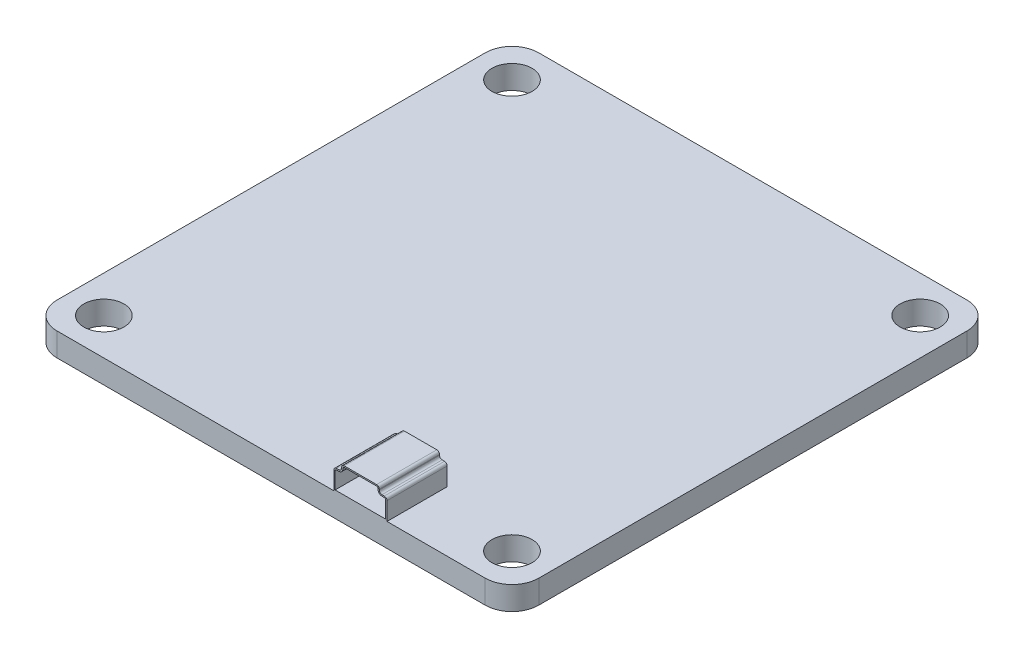
from build123d import *

# Parameters (mm, degrees)
SKETCH1_R           = 1.5
BOSS_EXTRUDE1_DEPTH = 1.75
BOSS_DEPTH          = 3
BOSS_EXTRUDE5_DEPTH = 1.5
SKETCH10_R          = 0.25
CUT_EXTRUDE2_DEPTH  = 5.5


with BuildPart() as part:
    # Sketch1 → Boss-Extrude1 (new body)
    with BuildSketch(Plane(origin=(0, 0, 0), x_dir=(1, 0, 0), z_dir=(0, 1, 0))):
        with BuildLine():
            Line((-16, -18), (16, -18))
            ThreePointArc((16, -18), (17.414213562, -17.414213562), (18, -16))
            Line((18, -16), (18, 16))
            ThreePointArc((18, 16), (17.414213562, 17.414213562), (16, 18))
            Line((16, 18), (-16, 18))
            ThreePointArc((-16, 18), (-17.414213562, 17.414213562), (-18, 16))
            Line((-18, 16), (-18, -16))
            ThreePointArc((-18, -16), (-17.414213562, -17.414213562), (-16, -18))
        make_face()
        with Locations((-15.25, 15.25)):
            Circle(SKETCH1_R, mode=Mode.SUBTRACT)
        with Locations((15.25, 15.25)):
            Circle(SKETCH1_R, mode=Mode.SUBTRACT)
        with Locations((-15.25, -15.25)):
            Circle(SKETCH1_R, mode=Mode.SUBTRACT)
        with Locations((15.25, -15.25)):
            Circle(SKETCH1_R, mode=Mode.SUBTRACT)
    extrude(amount=BOSS_EXTRUDE1_DEPTH)

    # Sketch2 → Boss- (add)
    with BuildSketch(Plane.XY.offset(18)):
        with BuildLine():
            Line((4.683071404, 1.75), (8.659974309, 1.75))
            Line((8.659974309, 1.75), (8.659974309, 3.094003243))
            ThreePointArc((8.659974309, 3.094003243), (8.601395665, 3.235424599), (8.459974309, 3.294003243))
            Line((8.459974309, 3.294003243), (8.281537536, 3.294003243))
            ThreePointArc((8.281537536, 3.294003243), (8.14011618, 3.352581887), (8.081537536, 3.494003243))
            Line((8.081537536, 3.494003243), (8.081537536, 3.55))
            ThreePointArc((8.081537536, 3.55), (8.022958893, 3.691421356), (7.881537536, 3.75))
            Line((7.881537536, 3.75), (5.461508176, 3.75))
            ThreePointArc((5.461508176, 3.75), (5.32008682, 3.691421356), (5.261508176, 3.55))
            Line((5.261508176, 3.55), (5.261508176, 3.494003243))
            ThreePointArc((5.261508176, 3.494003243), (5.202929533, 3.352581887), (5.061508176, 3.294003243))
            Line((5.061508176, 3.294003243), (4.883071404, 3.294003243))
            ThreePointArc((4.883071404, 3.294003243), (4.741650048, 3.235424599), (4.683071404, 3.094003243))
            Line((4.683071404, 3.094003243), (4.683071404, 1.75))
        make_face()
        with BuildLine():
            Line((4.783071404, 1.85), (4.783071404, 3.094003243))
            ThreePointArc((4.783071404, 3.094003243), (4.812360726, 3.164713921), (4.883071404, 3.194003243))
            Line((4.883071404, 3.194003243), (5.061508176, 3.194003243))
            ThreePointArc((5.061508176, 3.194003243), (5.273640211, 3.281871209), (5.361508176, 3.494003243))
            Line((5.361508176, 3.494003243), (5.361508176, 3.55))
            ThreePointArc((5.361508176, 3.55), (5.390797498, 3.620710678), (5.461508176, 3.65))
            Line((5.461508176, 3.65), (7.881537536, 3.65))
            ThreePointArc((7.881537536, 3.65), (7.952248214, 3.620710678), (7.981537536, 3.55))
            Line((7.981537536, 3.55), (7.981537536, 3.494003243))
            ThreePointArc((7.981537536, 3.494003243), (8.069405502, 3.281871209), (8.281537536, 3.194003243))
            Line((8.281537536, 3.194003243), (8.459974309, 3.194003243))
            ThreePointArc((8.459974309, 3.194003243), (8.530684987, 3.164713921), (8.559974309, 3.094003243))
            Line((8.559974309, 3.094003243), (8.559974309, 1.85))
            Line((8.559974309, 1.85), (4.783071404, 1.85))
        make_face(mode=Mode.SUBTRACT)
    extrude(amount=-BOSS_DEPTH)

    # Sketch9 → Boss-Extrude5 (add)
    with BuildSketch(Plane(origin=(0, 0, 15), x_dir=(-1, 0, 0), z_dir=(0, 0, -1))):
        with BuildLine():
            Line((-8.281537536, 3.294003243), (-8.459974309, 3.294003243))
            ThreePointArc((-8.459974309, 3.294003243), (-8.601395665, 3.235424599), (-8.659974309, 3.094003243))
            Line((-8.659974309, 3.094003243), (-8.659974309, 1.75))
            Line((-8.659974309, 1.75), (-4.683071404, 1.75))
            Line((-4.683071404, 1.75), (-4.683071404, 3.094003243))
            ThreePointArc((-4.683071404, 3.094003243), (-4.741650048, 3.235424599), (-4.883071404, 3.294003243))
            Line((-4.883071404, 3.294003243), (-5.061508176, 3.294003243))
            ThreePointArc((-5.061508176, 3.294003243), (-5.202929533, 3.352581887), (-5.261508176, 3.494003243))
            Line((-5.261508176, 3.494003243), (-5.261508176, 3.55))
            ThreePointArc((-5.261508176, 3.55), (-5.32008682, 3.691421356), (-5.461508176, 3.75))
            Line((-5.461508176, 3.75), (-7.881537536, 3.75))
            ThreePointArc((-7.881537536, 3.75), (-8.022958893, 3.691421356), (-8.081537536, 3.55))
            Line((-8.081537536, 3.55), (-8.081537536, 3.494003243))
            ThreePointArc((-8.081537536, 3.494003243), (-8.14011618, 3.352581887), (-8.281537536, 3.294003243))
        make_face()
    extrude(amount=BOSS_EXTRUDE5_DEPTH)

    # Sketch10 → Cut-Extrude2 (cut, through all)
    with BuildSketch(Plane(origin=(0, 0, 13.5), x_dir=(-1, 0, 0), z_dir=(0, 0, -1))):
        with Locations((-6.686931658, 2.562814542)):
            Circle(SKETCH10_R)
        with Locations((-5.886931658, 2.562814542)):
            Circle(SKETCH10_R)
        with Locations((-7.486931658, 2.562814542)):
            Circle(SKETCH10_R)
    extrude(amount=-CUT_EXTRUDE2_DEPTH, mode=Mode.SUBTRACT)


solid = part.part
